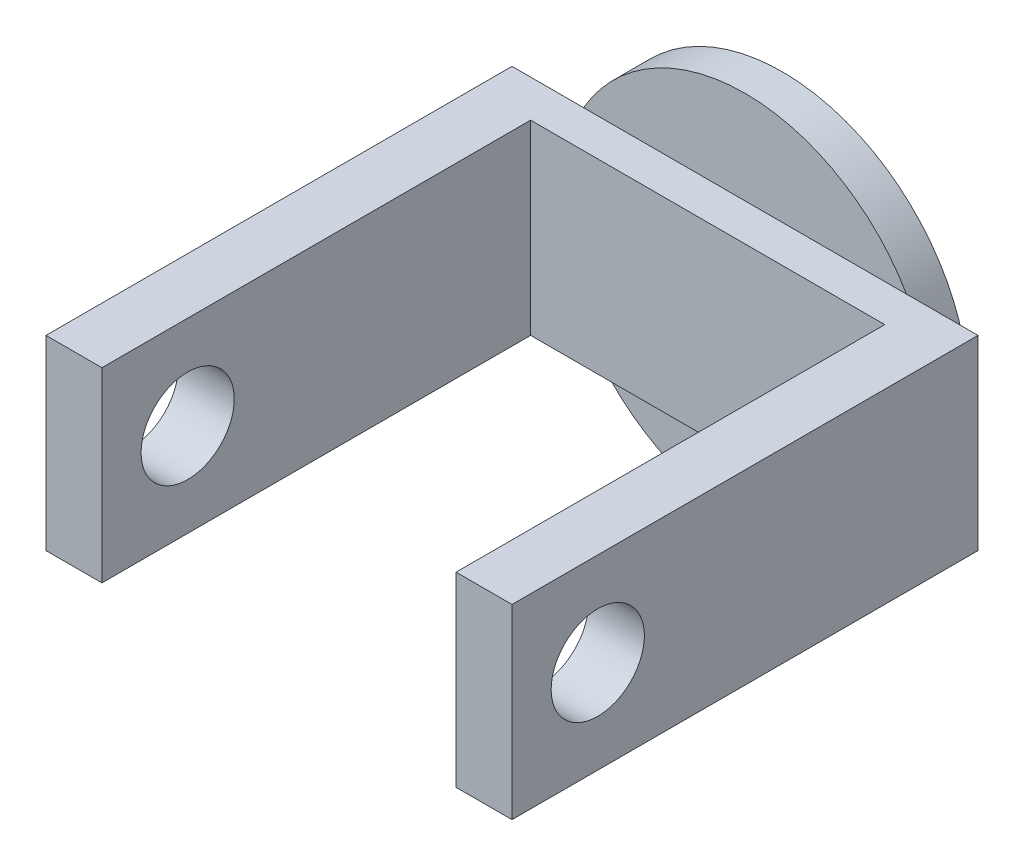
from build123d import *

# Parameters (mm, degrees)
SKETCH1_R           = 50
BOSS_EXTRUDE1_DEPTH = 10
SKETCH2_W           = 125
SKETCH2_H           = 50
BOSS_EXTRUDE2_DEPTH = 10
SKETCH3_W           = 15
SKETCH3_H           = 50
BOSS_EXTRUDE3_DEPTH = 115
SKETCH4_R           = 12.5
CUT_EXTRUDE1_DEPTH  = 126


with BuildPart() as part:
    # Sketch1 → Boss-Extrude1 (new body)
    with BuildSketch(Plane.XY):
        Circle(SKETCH1_R)
    extrude(amount=BOSS_EXTRUDE1_DEPTH)

    # Sketch2 → Boss-Extrude2 (add)
    with BuildSketch(Plane.XY.offset(10)):
        Rectangle(SKETCH2_W, SKETCH2_H)
    extrude(amount=BOSS_EXTRUDE2_DEPTH)

    # Sketch3 → Boss-Extrude3 (add)
    with BuildSketch(Plane.XY.offset(20)):
        with Locations((-55, 0)):
            Rectangle(SKETCH3_W, SKETCH3_H)
        with Locations((55, 0)):
            Rectangle(SKETCH3_W, SKETCH3_H)
    extrude(amount=BOSS_EXTRUDE3_DEPTH)

    # Sketch4 → Cut-Extrude1 (cut, through all)
    with BuildSketch(Plane.ZY.offset(62.5)):
        with Locations((112, 0)):
            Circle(SKETCH4_R)
    extrude(amount=-CUT_EXTRUDE1_DEPTH, mode=Mode.SUBTRACT)


solid = part.part
